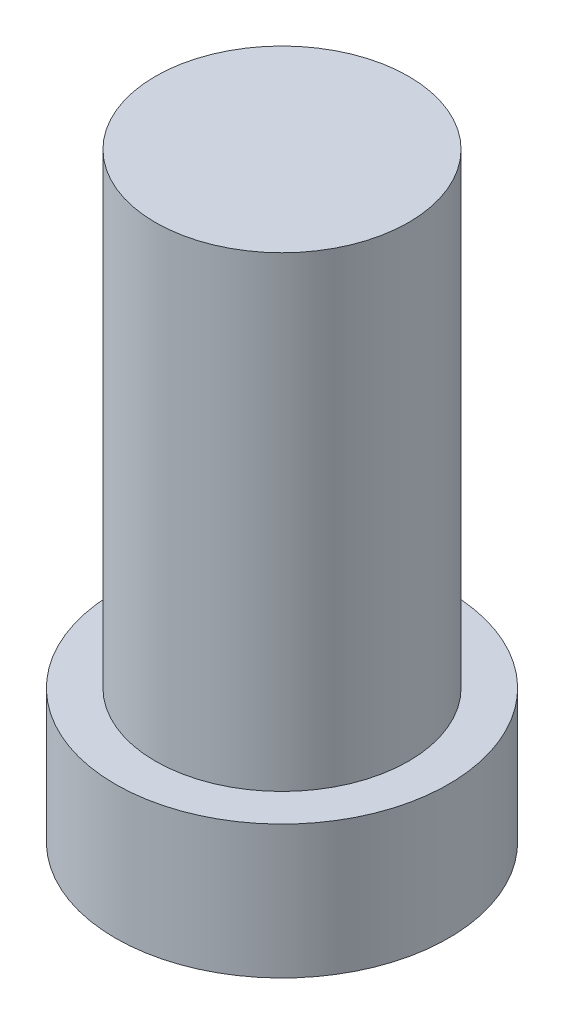
from build123d import *

# Parameters (mm, degrees)
SKETCH_1_R          = 5
EXTRUDE_1_DEPTH     = 4
SKETCH_2_R          = 3.8
EXTRUDE_2_DEPTH     = 14
SKETCH_3_R          = 3.5
SKETCH_3_R_2        = 0.75
CUT_EXTRUDE_1_DEPTH = 3


with BuildPart() as part:
    # 草图1 → 凸台-拉伸1 (new body)
    with BuildSketch(Plane(origin=(0, 0, 0), x_dir=(1, 0, 0), z_dir=(0, 1, 0))):
        Circle(SKETCH_1_R)
    extrude(amount=EXTRUDE_1_DEPTH)

    # 草图2 → 凸台-拉伸2 (add)
    with BuildSketch(Plane(origin=(0, 4, 0), x_dir=(1, 0, 0), z_dir=(0, 1, 0))):
        Circle(SKETCH_2_R)
    extrude(amount=EXTRUDE_2_DEPTH)

    # 草图3 → 切除-拉伸1 (cut)
    with BuildSketch(Plane.XZ):
        Circle(SKETCH_3_R)
        Circle(SKETCH_3_R_2, mode=Mode.SUBTRACT)
    extrude(amount=-CUT_EXTRUDE_1_DEPTH, mode=Mode.SUBTRACT)


solid = part.part
